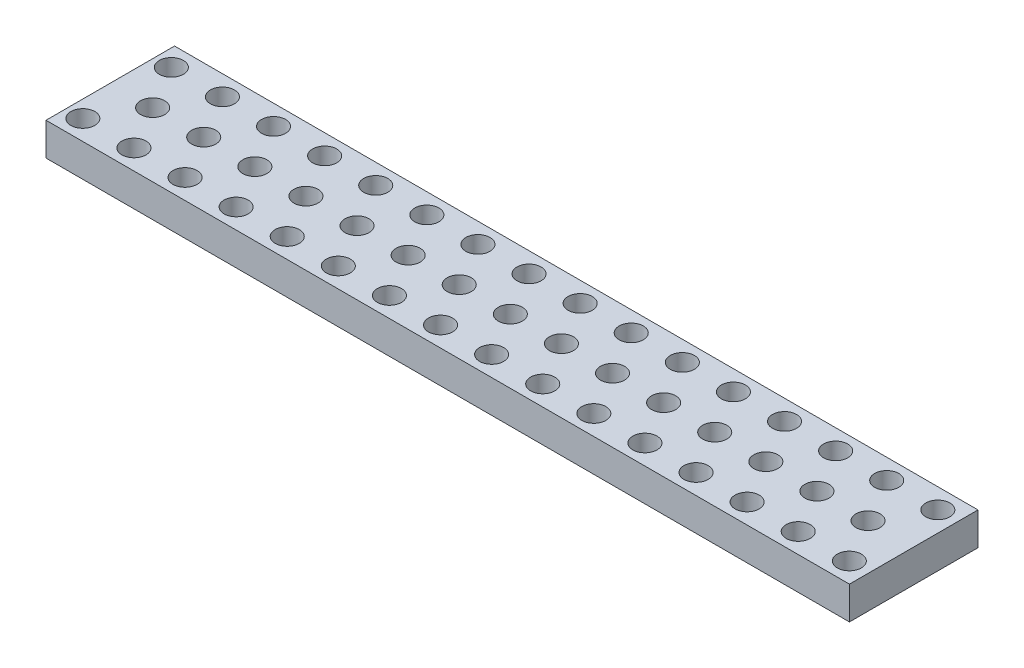
from build123d import *

# Parameters (mm, degrees)
SKETCH1_W               = 635
SKETCH1_H               = 101.6
BOSS_EXTRUDE1_DEPTH     = 25.908
SKETCH1_3_R             = 9.525
CUT_EXTRUDE1_DEPTH      = 602.644886082
LPATTERN1_COUNT         = 15
LPATTERN1_PITCH         = 40.386
CUT_EXTRUDE2_DEPTH      = 602.644886082
CUT_EXTRUDE2_DEPTH_BACK = 602.644886082
SKETCH2_R               = 9.525


with BuildPart() as part:
    # Sketch1 → Boss-Extrude1 (new body)
    with BuildSketch(Plane(origin=(0, 0, 0), x_dir=(1, 0, 0), z_dir=(0, 1, 0))):
        with Locations((-281.432, 0.0508)):
            Rectangle(SKETCH1_W, SKETCH1_H)
    extrude(amount=-BOSS_EXTRUDE1_DEPTH)

    # Sketch1_3 → Cut-Extrude1 (cut, symmetric)
    with BuildSketch(Plane(origin=(0, 0, 0), x_dir=(1, 0, 0), z_dir=(0, 1, 0))):
        Circle(SKETCH1_3_R)
        with Locations((20.193, 34.9758)):
            Circle(SKETCH1_3_R)
        with Locations((20.193, -34.9758)):
            Circle(SKETCH1_3_R)
    cut_extrude1 = extrude(amount=CUT_EXTRUDE1_DEPTH, both=True, mode=Mode.SUBTRACT)

    # LPattern1: Cut-Extrude1 ×15
    with Locations(*[(-i * LPATTERN1_PITCH, 0, 0) for i in range(1, LPATTERN1_COUNT)]):
        add(cut_extrude1, mode=Mode.SUBTRACT)

    # Sketch2 → Cut-Extrude2 (cut, two sides: drawn at the far end of the back side and taken through both)
    with BuildSketch(Plane(origin=(0, 0, 0), x_dir=(1, 0, 0), z_dir=(0, 1, 0)).offset(-CUT_EXTRUDE2_DEPTH_BACK)):
        with Locations((-585.597, 34.9758)):
            Circle(SKETCH2_R)
        with Locations((-585.597, -34.9758)):
            Circle(SKETCH2_R)
    extrude(amount=CUT_EXTRUDE2_DEPTH + CUT_EXTRUDE2_DEPTH_BACK, mode=Mode.SUBTRACT)


solid = part.part
